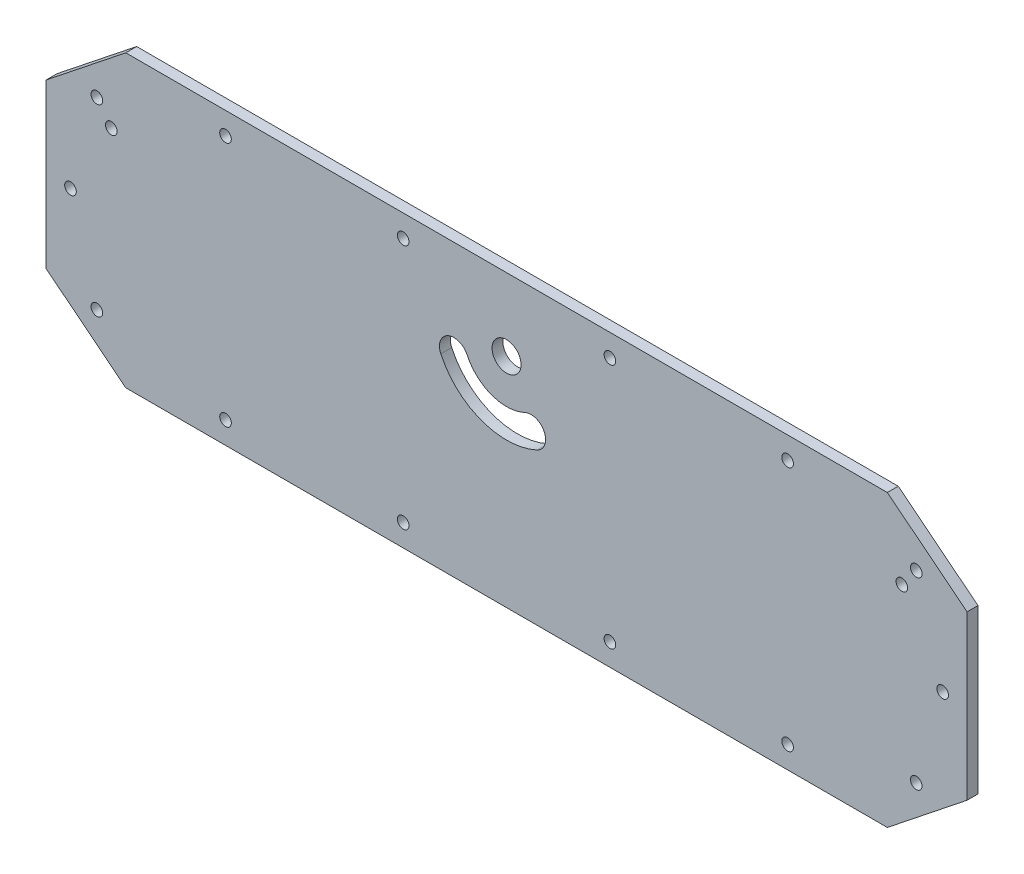
from build123d import *

# Parameters (mm, degrees)
CROQUIS1_R              = 4
CROQUIS1_R_2            = 1.6
SALIENTE_EXTRUIR1_DEPTH = 3


with BuildPart() as part:
    # Croquis1 → Saliente-Extruir1 (new body)
    with BuildSketch(Plane.XY):
        Polygon((-127, 22.5), (-105, 40), (105, 40), (127, 22.5), (127, -22.5), (105, -40), (-105, -40), (-127, -22.5), align=None)
        with Locations((0, 20)):
            Circle(CROQUIS1_R, mode=Mode.SUBTRACT)
        with Locations((112.98, 25.35)):
            Circle(CROQUIS1_R_2, mode=Mode.SUBTRACT)
        with Locations((120.25, 0)):
            Circle(CROQUIS1_R_2, mode=Mode.SUBTRACT)
        with Locations((112.98, -25.35)):
            Circle(CROQUIS1_R_2, mode=Mode.SUBTRACT)
        with Locations((77.5, -33.9)):
            Circle(CROQUIS1_R_2, mode=Mode.SUBTRACT)
        with Locations((28.5, -33.9)):
            Circle(CROQUIS1_R_2, mode=Mode.SUBTRACT)
        with Locations((-28.5, -33.9)):
            Circle(CROQUIS1_R_2, mode=Mode.SUBTRACT)
        with Locations((-77.5, -33.9)):
            Circle(CROQUIS1_R_2, mode=Mode.SUBTRACT)
        with Locations((-112.98, -25.35)):
            Circle(CROQUIS1_R_2, mode=Mode.SUBTRACT)
        with Locations((-120.25, 0)):
            Circle(CROQUIS1_R_2, mode=Mode.SUBTRACT)
        with Locations((-112.98, 25.35)):
            Circle(CROQUIS1_R_2, mode=Mode.SUBTRACT)
        with Locations((-77.5, 33.9)):
            Circle(CROQUIS1_R_2, mode=Mode.SUBTRACT)
        with Locations((-28.5, 33.9)):
            Circle(CROQUIS1_R_2, mode=Mode.SUBTRACT)
        with Locations((28.5, 33.9)):
            Circle(CROQUIS1_R_2, mode=Mode.SUBTRACT)
        with Locations((77.5, 33.9)):
            Circle(CROQUIS1_R_2, mode=Mode.SUBTRACT)
        with Locations((-109, 20)):
            Circle(CROQUIS1_R_2, mode=Mode.SUBTRACT)
        with Locations((109, 20)):
            Circle(CROQUIS1_R_2, mode=Mode.SUBTRACT)
        with BuildLine():
            ThreePointArc((-18.126155741, 11.547634765), (-6.840402867, 1.206147584), (8.452365235, 1.873844259))
            ThreePointArc((8.452365235, 1.873844259), (10.387123336, 7.189548454), (5.071419141, 9.124306556))
            ThreePointArc((5.071419141, 9.124306556), (-4.10424172, 8.723688551), (-10.875693444, 14.928580859))
            ThreePointArc((-10.875693444, 14.928580859), (-16.19139764, 16.86333896), (-18.126155741, 11.547634765))
        make_face(mode=Mode.SUBTRACT)
    extrude(amount=SALIENTE_EXTRUIR1_DEPTH)


solid = part.part
